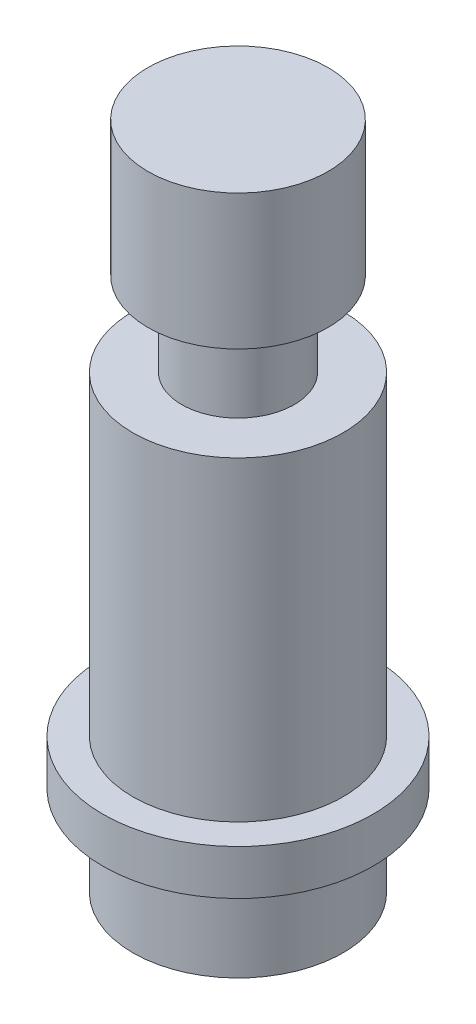
from build123d import *


with BuildPart() as part:
    # Sketch1 → Revolve1 (revolve)
    with BuildSketch(Plane(origin=(0, 0, 0), x_dir=(0, 0, -1), z_dir=(1, 0, 0))):
        Polygon((0, 0), (-7, 0), (-7, 6), (-9, 6), (-9, 9), (-7, 9), (-7, 30), (-3.75, 30), (-3.75, 35.573874856), (-6, 35.573874856), (-6, 44.573874856), (0, 44.573874856), align=None)
    revolve(axis=Axis((0, 0, 0), (0, 1, 0)))


solid = part.part
